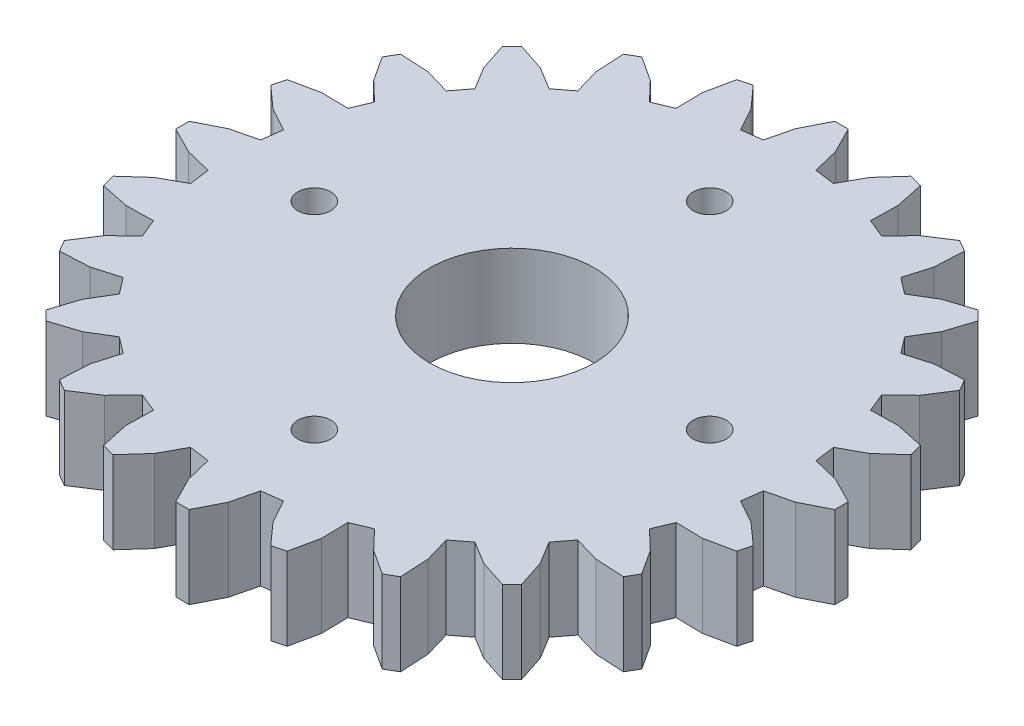
from build123d import *

# Parameters (mm, degrees)
BOSS_EXTRUDE1_DEPTH = 5
SKETCH4_R           = 5
CUT_EXTRUDE1_DEPTH  = 5
SKETCH5_R           = 1
CUT_EXTRUDE2_DEPTH  = 5


with BuildPart() as part:
    # Sketch2 → Boss-Extrude1 (new body)
    with BuildSketch(Plane(origin=(0, 0, 0), x_dir=(1, 0, 0), z_dir=(0, 1, 0))):
        Polygon((62.172127475, 64.438287146), (63.746631591, 64.052516421), (65.320772998, 63.251970245), (65.320772998, 62.437646696), (63.746631591, 61.63710052), (62.172127475, 61.251330223), (62.010422663, 60.022472316), (63.431319755, 59.242350893), (64.744655445, 58.061714434), (64.533883435, 57.275066391), (62.806134576, 56.909358138), (61.185584837, 56.944164493), (60.711227056, 55.799059379), (61.881832707, 54.677762874), (62.844929445, 53.197526256), (62.437646696, 52.492214089), (60.674124543, 52.585997689), (59.117748594, 53.03908454), (58.363248469, 52.055804998), (59.203797973, 50.66971469), (59.750789184, 48.990670319), (59.174913579, 48.414794286), (57.495869208, 48.961785926), (56.1097789, 49.80233543), (55.126499358, 49.047834876), (55.579586209, 47.491459356), (55.67336981, 45.727937202), (54.968057642, 45.320654453), (53.487820596, 46.283751191), (52.366524519, 47.454356415), (51.221419405, 46.979999061), (51.25622576, 45.359448894), (50.890517507, 43.631700463), (50.103869465, 43.420928454), (48.923233005, 44.734264143), (48.143111582, 46.155161235), (46.914253675, 45.993456423), (46.528483378, 44.418952307), (45.727937202, 42.8448109), (44.913613653, 42.8448109), (44.113067477, 44.418952307), (43.727296752, 45.993456423), (42.498439273, 46.155161235), (41.718317422, 44.734264143), (40.537680963, 43.420928454), (39.751033348, 43.631700463), (39.385325095, 45.359448894), (39.420131451, 46.979999061), (38.275026336, 47.454356415), (37.153729831, 46.283751191), (35.673492785, 45.320654453), (34.968181046, 45.727937202), (35.061964647, 47.491459356), (35.515051497, 49.047834876), (34.531771955, 49.80233543), (33.145681219, 48.961785926), (31.466637276, 48.414794286), (30.890761243, 48.990670319), (31.437752883, 50.66971469), (32.278302387, 52.055804998), (31.523801833, 53.03908454), (29.967425885, 52.585997689), (28.20390416, 52.492214089), (27.796621411, 53.197526256), (28.759718149, 54.677762874), (29.930323372, 55.799059379), (29.455966018, 56.944164493), (27.835415852, 56.909358138), (26.107666992, 57.275066391), (25.896895411, 58.061714434), (27.210231101, 59.242350893), (28.631127764, 60.022472316), (28.46942338, 61.251330223), (26.894919264, 61.63710052), (25.320777429, 62.437646696), (25.320777429, 63.251970245), (26.894919264, 64.052516421), (28.46942338, 64.438287146), (28.631127764, 65.667144625), (27.210231101, 66.447266476), (25.896895411, 67.627902507), (26.107666992, 68.41455055), (27.835415852, 68.780258803), (29.455966018, 68.745452448), (29.930323372, 69.890557562), (28.759718149, 71.011854067), (27.796621411, 72.492090685), (28.20390416, 73.197402852), (29.967425885, 73.103619252), (31.523801833, 72.650532401), (32.278302387, 73.633811943), (31.437752883, 75.019902251), (30.890761243, 76.698946622), (31.466637276, 77.274822655), (33.145681219, 76.727831015), (34.531771955, 75.887281511), (35.515051497, 76.641782065), (35.061964647, 78.198157585), (34.968181046, 79.961679739), (35.673492785, 80.368962487), (37.153729831, 79.40586575), (38.275026336, 78.235260526), (39.420131451, 78.70961788), (39.385325095, 80.330168047), (39.751033348, 82.057916906), (40.537680963, 82.268688487), (41.718317422, 80.955352798), (42.498439273, 79.534456134), (43.727296752, 79.696160518), (44.113067477, 81.270664634), (44.913613653, 82.844806041), (45.727937202, 82.844806041), (46.528483378, 81.270664634), (46.914253675, 79.696160518), (48.143111582, 79.534456134), (48.923233005, 80.955352798), (50.103869465, 82.268688487), (50.890517507, 82.057916906), (51.25622576, 80.330168047), (51.221419405, 78.70961788), (52.366524519, 78.235260526), (53.487820596, 79.40586575), (54.968057642, 80.368962487), (55.67336981, 79.961679739), (55.579586209, 78.198157585), (55.126499358, 76.641782065), (56.1097789, 75.887281511), (57.495869208, 76.727831015), (59.174913579, 77.274822655), (59.750789184, 76.698946622), (59.203797973, 75.019902251), (58.363248469, 73.633811943), (59.117748594, 72.650532401), (60.674124543, 73.103619252), (62.437646696, 73.197402852), (62.844929445, 72.492090685), (61.881832707, 71.011854067), (60.711227056, 69.890557562), (61.185584837, 68.745452448), (62.806134576, 68.780258803), (64.533883435, 68.41455055), (64.744655445, 67.627902507), (63.431319755, 66.447266476), (62.010422663, 65.667144625), align=None)
    extrude(amount=BOSS_EXTRUDE1_DEPTH)

    # Sketch4 → Cut-Extrude1 (cut)
    with BuildSketch(Plane(origin=(0, 0, 0), x_dir=(1, 0, 0), z_dir=(0, 1, 0))):
        with Locations((45.320775214, 62.84480847)):
            Circle(SKETCH4_R)
    extrude(amount=CUT_EXTRUDE1_DEPTH, mode=Mode.SUBTRACT)

    # Sketch5 → Cut-Extrude2 (cut)
    with BuildSketch(Plane(origin=(0, 0, 0), x_dir=(1, 0, 0), z_dir=(0, 1, 0))):
        with Locations((45.320775428, 50.84480847)):
            Circle(SKETCH5_R)
        with Locations((33.320775428, 62.84480847)):
            Circle(SKETCH5_R)
        with Locations((45.320775428, 74.84480847)):
            Circle(SKETCH5_R)
        with Locations((57.320775428, 62.84480847)):
            Circle(SKETCH5_R)
    extrude(amount=CUT_EXTRUDE2_DEPTH, mode=Mode.SUBTRACT)


solid = part.part
